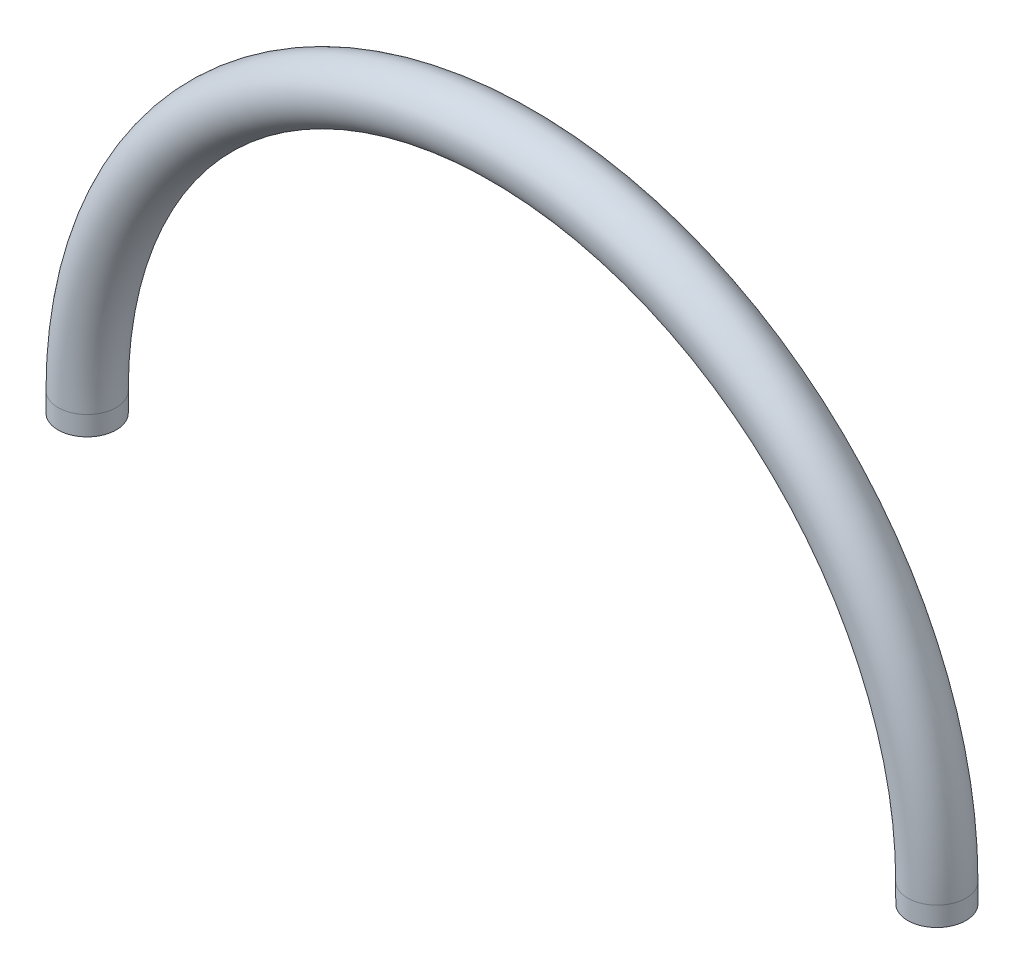
from build123d import *

# Parameters (mm, degrees)
SWEEP1_PROFILE_R = 3.81


with BuildPart() as part:
    # Sweep1: sweep along a path in Sketch2
    with BuildLine(Plane.XY) as sweep1_path:
        Line((-55.626, -2.54), (-55.626, 0))
        ThreePointArc((-55.626, 0), (0, 55.626), (55.626, 0))
        Line((55.626, 0), (55.626, -2.54))
    # Sweep1 profile (on start of the path) → Sweep1 (sweep)
    with BuildSketch(Plane(origin=(-55.626, -2.54, 0), x_dir=(1, 0, 0), z_dir=(0, 1, 0))):
        Circle(SWEEP1_PROFILE_R)
    sweep(path=sweep1_path.line)


solid = part.part
